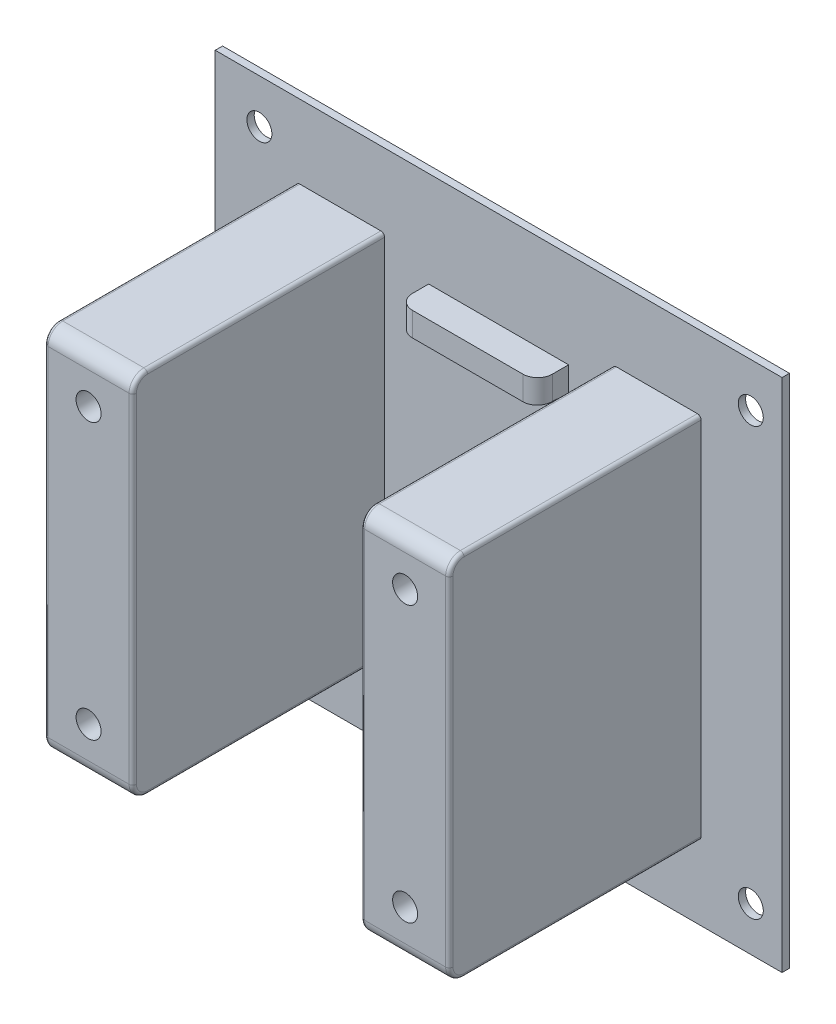
from build123d import *

# Parameters (mm, degrees)
MOUNT_BASE_DEPTH               = 10
SKETCH_8_W                     = 38
SKETCH_8_H                     = 31
CUT_BASE_DEPTH                 = 34
SKETCH10_W                     = 3
SKETCH10_H                     = 31
BEND_SIDES_DEPTH               = 34.2
SKETCH16_W                     = 44
SKETCH16_H                     = 3
WIRE_SIDES_DEPTH               = 34.2
DRAFT9_ANGLE                   = 1
DRAFT10_ANGLE                  = 1
DIFFERENTIAL_CLAMP_DEPTH       = 10
DIFFERENTIAL_CLAMP_DEPTH_BACK  = 8.6
DIFFERENTIAL_BAR_CUT_DEPTH     = 3.6
STRUCTURAL_SCREW_W_HEADS_DEPTH = 5
SKETCH25_R                     = 1.7
SCREW_HOLES_DEPTH              = 24
NUT_HOLE_DEPTH                 = 2.6
FILLET7_R                      = 2
FILLET8_R                      = 2
FILLET9_R                      = 2
FILLET10_R                     = 2
FILLET15_R                     = 2
BOSS_EXTRUDE1_DEPTH            = 17.6
CUT_EXTRUDE6_DEPTH             = 8.6
SKETCH48_W                     = 74
SKETCH48_H                     = 70
CUT_EXTRUDE9_DEPTH             = 17.6
SKETCH49_W                     = 77
SKETCH49_H                     = 70
BOSS_EXTRUDE2_DEPTH            = 1
SKETCH50_R                     = 1.7
CUT_EXTRUDE10_DEPTH            = 1
CUT_EXTRUDE12_DEPTH            = 34.2
SKETCH53_W                     = 19
SKETCH53_H                     = 5.77151387
CUT_EXTRUDE13_DEPTH            = 30
FILLET17_R                     = 2
BOSS_EXTRUDE3_DEPTH            = 34.2
CUT_EXTRUDE14_DEPTH            = 2.6
SKETCH56_R                     = 1.7
CUT_EXTRUDE15_DEPTH            = 8
FILLET18_R                     = 2
FILLET20_R                     = 0.5


with BuildPart() as part:
    # Sketch6 → Mount Base (new body)
    with BuildSketch(Plane(origin=(0, 0, 0), x_dir=(0, 1, 0), z_dir=(0, 0, 1))):
        Polygon((-30, -26.5), (-30, -31.5), (30, -31.5), (30, -26.5), (30, 26.5), (-30, 26.5), align=None)
    extrude(amount=MOUNT_BASE_DEPTH)

    # Sketch 8 → Cut-Base (cut)
    with BuildSketch(Plane(origin=(0, 0, 7), x_dir=(0, 1, 0), z_dir=(0, 0, 1))):
        Rectangle(SKETCH_8_W, SKETCH_8_H)
    extrude(amount=CUT_BASE_DEPTH, mode=Mode.SUBTRACT)

    # Sketch10 → Bend Sides (add)
    with BuildSketch(Plane(origin=(0, 0, 10), x_dir=(0, 1, 0), z_dir=(0, 0, 1))):
        with Locations((-20.5, 0)):
            Rectangle(SKETCH10_W, SKETCH10_H)
        with Locations((20.5, 0)):
            Rectangle(SKETCH10_W, SKETCH10_H)
    extrude(amount=BEND_SIDES_DEPTH)

    # Sketch16 → Wire Sides (add)
    with BuildSketch(Plane(origin=(0, 0, 10), x_dir=(0, 1, 0), z_dir=(0, 0, 1))):
        with Locations((0, -17)):
            Rectangle(SKETCH16_W, SKETCH16_H)
        with Locations((0, 17)):
            Rectangle(SKETCH16_W, SKETCH16_H)
    extrude(amount=WIRE_SIDES_DEPTH)

    # Draft9
    draft9_faces = [part.faces().sort_by_distance(p)[0] for p in [
        (0, -19, 25.6),
    ]]
    draft(draft9_faces, Plane(origin=(0, 0, 0), x_dir=(-1, 0, 0), z_dir=(0, 0, -1)), DRAFT9_ANGLE)

    # Draft10
    draft10_faces = [part.faces().sort_by_distance(p)[0] for p in [
        (0, 19, 25.6),
    ]]
    draft(draft10_faces, Plane(origin=(0, 0, 0), x_dir=(-1, 0, 0), z_dir=(0, 0, -1)), DRAFT10_ANGLE)

    # Sketch20 → Differential Clamp (add, two sides)
    with BuildSketch(Plane(origin=(0, 0, 0), x_dir=(0, 1, 0), z_dir=(0, 0, 1))) as differential_clamp_sk:
        Polygon((-30, 37), (-30, 26.5), (-30, -37), (30, -37), (30, 27), (30, 37), align=None)
    extrude(amount=DIFFERENTIAL_CLAMP_DEPTH)
    extrude(differential_clamp_sk.sketch, amount=-DIFFERENTIAL_CLAMP_DEPTH_BACK)

    # Sketch22 → Differential Bar cut (cut)
    with BuildSketch(Plane(origin=(0, 0, 0), x_dir=(0, 1, 0), z_dir=(0, 0, 1))):
        Polygon((-86.956180584, -24.693764348), (0, -30.5), (86.956180584, -24.693764348), (86.956180584, 37), (30, 37), (-30, 37), (-86.956180584, 37), align=None)
    extrude(amount=-DIFFERENTIAL_BAR_CUT_DEPTH, mode=Mode.SUBTRACT)

    # Sketch 7 → Structural Screw w/ heads (cut)
    with BuildSketch(Plane(origin=(0, 0, 0), x_dir=(0, 1, 0), z_dir=(0, 0, 1))):
        with BuildLine():
            Line((-22.42, 37.163783556), (-22.42, -19.42))
            ThreePointArc((-22.42, -19.42), (-19.42, -22.42), (-16.42, -19.42))
            Line((-16.42, -19.42), (-16.42, 37.163783556))
            Line((-16.42, 37.163783556), (-22.42, 37.163783556))
        make_face()
        with BuildLine():
            Line((16.42, -19.42), (16.42, 37.161181528))
            Line((16.42, 37.161181528), (22.42, 37.161181528))
            Line((22.42, 37.161181528), (22.42, -19.42))
            ThreePointArc((22.42, -19.42), (19.42, -22.42), (16.42, -19.42))
        make_face()
        with BuildLine():
            Line((-3, 37.161181528), (3, 37.161181528))
            Line((3, 37.161181528), (3, -10.32))
            ThreePointArc((3, -10.32), (0, -13.32), (-3, -10.32))
            Line((-3, -10.32), (-3, 37.161181528))
        make_face()
    extrude(amount=STRUCTURAL_SCREW_W_HEADS_DEPTH, mode=Mode.SUBTRACT)

    # Sketch25 → Screw holes (cut)
    with BuildSketch(Plane.XY.offset(10)):
        with Locations((-32, 29)):
            Circle(SKETCH25_R)
        with Locations((-32, -29)):
            Circle(SKETCH25_R)
        with Locations((32, -29)):
            Circle(SKETCH25_R)
        with Locations((32, 29)):
            Circle(SKETCH25_R)
    extrude(amount=-SCREW_HOLES_DEPTH, mode=Mode.SUBTRACT)

    # Sketch27 → Nut hole (cut)
    with BuildSketch(Plane(origin=(0, 0, -8.6), x_dir=(-1, 0, 0), z_dir=(0, 0, -1))):
        Polygon((31.935113153, 25.709743217), (34.817002535, 27.29867795), (34.881889383, 30.588934733), (32.064886847, 32.290256783), (29.182997465, 30.70132205), (29.118110617, 27.411065267), align=None)
        Polygon((28.709103466, -29), (30.354551733, -31.85), (33.645448267, -31.85), (35.290896534, -29), (33.645448267, -26.15), (30.354551733, -26.15), align=None)
        Polygon((-30.354551733, -26.15), (-28.709103466, -29), (-30.354551733, -31.85), (-33.645448267, -31.85), (-35.290896534, -29), (-33.645448267, -26.15), align=None)
        Polygon((-29.118110617, 27.411065267), (-31.935113153, 25.709743217), (-34.817002535, 27.29867795), (-34.881889383, 30.588934733), (-32.064886847, 32.290256783), (-29.182997465, 30.70132205), align=None)
    extrude(amount=-NUT_HOLE_DEPTH, mode=Mode.SUBTRACT)

    # Fillet7
    fillet7_edges = [part.edges().sort_by_distance(p)[0] for p in [
        (-37, 30, 5),
    ]]
    fillet(fillet7_edges, radius=FILLET7_R)

    # Fillet8
    fillet8_edges = [part.edges().sort_by_distance(p)[0] for p in [
        (-37, -30, 5),
    ]]
    fillet(fillet8_edges, radius=FILLET8_R)

    # Fillet9
    fillet9_edges = [part.edges().sort_by_distance(p)[0] for p in [
        (-37, 30, -6.1),
    ]]
    fillet(fillet9_edges, radius=FILLET9_R)

    # Fillet10
    fillet10_edges = [part.edges().sort_by_distance(p)[0] for p in [
        (-37, -30, -6.1),
    ]]
    fillet(fillet10_edges, radius=FILLET10_R)

    # Fillet15
    fillet15_edges = [part.edges().sort_by_distance(p)[0] for p in [
        (0, 18.825449351, 10),
        (0, -18.825449351, 10),
    ]]
    fillet(fillet15_edges, radius=FILLET15_R)

    # Sketch42 → Boss-Extrude1 (add)
    with BuildSketch(Plane.XY.offset(-8.6)):
        Polygon((37, 35), (-37, 35), (-37, 23), (28.5, 23), (28.5, -23), (-37, -23), (-37, -35), (37, -35), align=None)
    extrude(amount=BOSS_EXTRUDE1_DEPTH)

    # Sketch43 → Cut-Extrude6 (cut)
    with BuildSketch(Plane(origin=(0, 0, 0), x_dir=(-1, 0, 0), z_dir=(0, 0, -1))):
        Polygon((-24.693764348, 86.956180584), (37, 86.956180584), (37, -86.956180584), (-24.693764348, -86.956180584), (-30.5, 0), align=None)
    extrude(amount=CUT_EXTRUDE6_DEPTH, mode=Mode.SUBTRACT)

    # Sketch48 → Cut-Extrude9 (cut)
    with BuildSketch(Plane.XY.offset(9)):
        Rectangle(SKETCH48_W, SKETCH48_H)
    extrude(amount=-CUT_EXTRUDE9_DEPTH, mode=Mode.SUBTRACT)

    # Sketch49 → Boss-Extrude2 (add)
    with BuildSketch(Plane.XY.offset(9)):
        Rectangle(SKETCH49_W, SKETCH49_H)
    extrude(amount=BOSS_EXTRUDE2_DEPTH)

    # Sketch50 → Cut-Extrude10 (cut)
    with BuildSketch(Plane.XY.offset(9)):
        with Locations((-32.5, 29)):
            Circle(SKETCH50_R)
        with Locations((34.25, 29)):
            Circle(SKETCH50_R)
        with Locations((34.25, -29)):
            Circle(SKETCH50_R)
        with Locations((-32.5, -29)):
            Circle(SKETCH50_R)
    extrude(amount=CUT_EXTRUDE10_DEPTH, mode=Mode.SUBTRACT)

    # Sketch52 → Cut-Extrude12 (cut)
    with BuildSketch(Plane.XY.offset(44.2)):
        Polygon((-15.5, 24.22848613), (-9.5, 24.22848613), (-9.5, 18.22848613), (-9.5, 16.790234565), (-15.5, 16.790234565), (-15.5, 18.22848613), align=None)
        Polygon((15.5, 18.22848613), (15.5, 16.790234565), (9.5, 16.790234565), (9.5, 18.22848613), (9.5, 24.22848613), (15.5, 24.22848613), align=None)
        Polygon((15.5, -18.22848613), (15.5, -24.22848613), (9.5, -24.22848613), (9.5, -18.22848613), (9.5, -16.790234565), (15.5, -16.790234565), align=None)
        Polygon((-15.5, -18.22848613), (-15.5, -16.790234565), (-9.5, -16.790234565), (-9.5, -18.22848613), (-9.5, -24.22848613), (-15.5, -24.22848613), align=None)
    extrude(amount=-CUT_EXTRUDE12_DEPTH, mode=Mode.SUBTRACT)

    # Sketch53 → Cut-Extrude13 (cut)
    with BuildSketch(Plane.XY.offset(44.2)):
        with Locations((0, -21.114243065)):
            Rectangle(SKETCH53_W, SKETCH53_H)
        with Locations((0, 19.114243065)):
            Rectangle(SKETCH53_W, SKETCH53_H)
    extrude(amount=-CUT_EXTRUDE13_DEPTH, mode=Mode.SUBTRACT)

    # Fillet17
    fillet17_edges = [part.edges().sort_by_distance(p)[0] for p in [
        (-9.5, -20.376069039, 14.2),
    ]]
    fillet(fillet17_edges, radius=FILLET17_R)

    # Sketch55 → Boss-Extrude3 (add)
    with BuildSketch(Plane.XY.offset(10)):
        Polygon((-18.5, 22), (-18.5, -22), (-15.5, -22), (-15.5, -25), (-27.5, -25), (-27.5, -22), (-27.5, 22), (-27.5, 25), (-15.5, 25), (-15.5, 22), align=None)
        Polygon((18.5, 22), (18.5, -22), (15.5, -22), (15.5, -25), (27.5, -25), (27.5, -22), (27.5, 22), (27.5, 25), (15.5, 25), (15.5, 22), align=None)
    extrude(amount=BOSS_EXTRUDE3_DEPTH)

    # Sketch54 → Cut-Extrude14 (cut)
    with BuildSketch(Plane.XY.offset(39.2)):
        Polygon((24.4, 20.359315781), (24.4, 17.010684219), (21.5, 15.336368439), (18.6, 17.010684219), (18.6, 20.359315781), (21.5, 22.033631561), align=None)
        Polygon((-24.4, 17.010684219), (-21.5, 15.336368439), (-18.6, 17.010684219), (-18.6, 20.359315781), (-21.5, 22.033631561), (-24.4, 20.359315781), align=None)
        Polygon((21.5, -22.033631561), (24.4, -20.359315781), (24.4, -17.010684219), (21.5, -15.336368439), (18.6, -17.010684219), (18.6, -20.359315781), align=None)
        Polygon((-24.4, -20.359315781), (-24.4, -17.010684219), (-21.5, -15.336368439), (-18.6, -17.010684219), (-18.6, -20.359315781), (-21.5, -22.033631561), align=None)
    extrude(amount=CUT_EXTRUDE14_DEPTH, mode=Mode.SUBTRACT)

    # Sketch56 → Cut-Extrude15 (cut)
    with BuildSketch(Plane.XY.offset(44.2)):
        with Locations((-21.5, 18.685)):
            Circle(SKETCH56_R)
        with Locations((21.5, 18.685)):
            Circle(SKETCH56_R)
        with Locations((21.5, -18.685)):
            Circle(SKETCH56_R)
        with Locations((-21.5, -18.685)):
            Circle(SKETCH56_R)
    extrude(amount=-CUT_EXTRUDE15_DEPTH, mode=Mode.SUBTRACT)

    # Fillet18
    fillet18_edges = [part.edges().sort_by_distance(p)[0] for p in [
        (9.5, -20.376069039, 14.2),
        (-9.5, 20.376069039, 14.2),
        (9.5, 20.376069039, 14.2),
        (-21.5, 25, 44.2),
        (-21.5, -25, 44.2),
        (21.5, -25, 44.2),
        (21.5, 25, 44.2),
    ]]
    fillet(fillet18_edges, radius=FILLET18_R)

    # Fillet20
    fillet20_edges = [part.edges().sort_by_distance(p)[0] for p in [
        (-27.5, 0, 44.2),
        (-27.5, -25, 26.1),
        (-27.5, 25, 26.1),
        (-27.5, -24.414213562, 43.614213562),
        (-27.5, 24.414213562, 43.614213562),
        (-15.5, 25, 26.1),
        (-15.5, -25, 26.1),
        (-15.5, -24.414213562, 43.614213562),
        (-15.5, 24.414213562, 43.614213562),
        (15.5, 0, 44.2),
        (27.5, 0, 44.2),
        (27.5, 25, 26.1),
        (27.5, -25, 26.1),
        (27.5, 24.414213562, 43.614213562),
        (27.5, -24.414213562, 43.614213562),
        (15.5, -25, 26.1),
        (15.5, 25, 26.1),
        (15.5, 24.414213562, 43.614213562),
        (15.5, -24.414213562, 43.614213562),
        (-15.5, 0, 44.2),
    ]]
    fillet(fillet20_edges, radius=FILLET20_R)


solid = part.part
